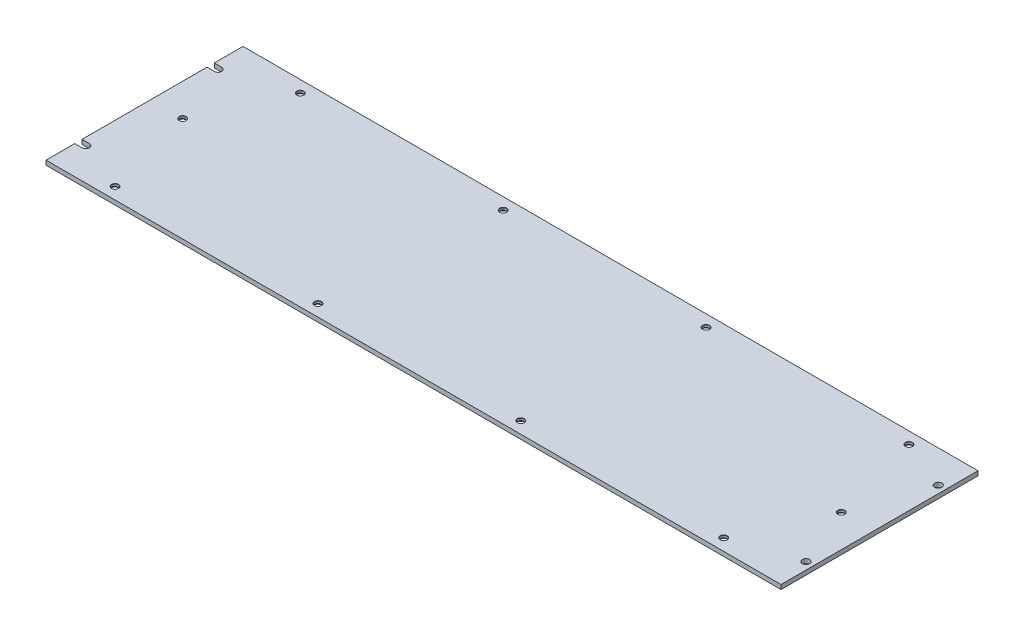
from build123d import *

# Parameters (mm, degrees)
SKETCH_2_W                  = 500
SKETCH_2_H                  = 134
EXTRUDE_1_DEPTH             = 3
SKETCH_3_R                  = 2.5
CUT_EXTRUDE_1_DEPTH         = 4
HOLE_WIZARD_M41_AT_2_COUNT  = 2
HOLE_WIZARD_M41_AT_2_PITCH  = 138
HOLE_WIZARD_M41_AT_3_COUNT  = 2
HOLE_WIZARD_M41_AT_3_PITCH  = 167.314075917
HOLE_WIZARD_M41_AT_4_COUNT  = 2
HOLE_WIZARD_M41_AT_4_PITCH  = 175.567650779
HOLE_WIZARD_M41_AT_5_COUNT  = 2
HOLE_WIZARD_M41_AT_5_PITCH  = 118.270875536
HOLE_WIZARD_M41_AT_6_COUNT  = 2
HOLE_WIZARD_M41_AT_6_PITCH  = 187.723200484
HOLE_WIZARD_M41_AT_7_COUNT  = 2
HOLE_WIZARD_M41_AT_7_PITCH  = 307.538615462
HOLE_WIZARD_M41_AT_8_COUNT  = 2
HOLE_WIZARD_M41_AT_8_PITCH  = 305.983659694
HOLE_WIZARD_M41_AT_9_COUNT  = 2
HOLE_WIZARD_M41_AT_9_PITCH  = 276
HOLE_WIZARD_M41_AT_10_COUNT = 2
HOLE_WIZARD_M41_AT_10_PITCH = 138


with BuildPart() as part:
    # Эскиз2 → Бобышка-Вытянуть1 (new body)
    with BuildSketch(Plane(origin=(0, 0, 0), x_dir=(1, 0, 0), z_dir=(0, 1, 0))):
        with Locations((250, 67)):
            Rectangle(SKETCH_2_W, SKETCH_2_H)
    extrude(amount=EXTRUDE_1_DEPTH)

    # Эскиз3 → Вырез-Вытянуть1 (cut, through all)
    with BuildSketch(Plane(origin=(0, 3, 0), x_dir=(1, 0, 0), z_dir=(0, 1, 0))):
        with BuildLine():
            ThreePointArc((5, 109.5), (7.5, 112), (5, 114.5))
            Line((5, 114.5), (0, 114.5))
            Line((0, 114.5), (0, 109.5))
            Line((0, 109.5), (5, 109.5))
        make_face()
        with BuildLine():
            Line((5, 24.5), (0, 24.5))
            Line((0, 24.5), (0, 19.5))
            Line((0, 19.5), (5, 19.5))
            ThreePointArc((5, 19.5), (7.5, 22), (5, 24.5))
        make_face()
        with Locations((495, 22)):
            Circle(SKETCH_3_R)
        with Locations((495, 112)):
            Circle(SKETCH_3_R)
    extrude(amount=-CUT_EXTRUDE_1_DEPTH, mode=Mode.SUBTRACT)

    # Эскиз4 → Зенковка для винта с потайной головкой M41 (revolve, cut)
    with BuildSketch(Plane(origin=(177, 0, -8), x_dir=(0, 0, -1), z_dir=(1, 0, 0))):
        Polygon((0, 0), (0, 3), (2.4, 3), (2.25, 2.85), (2.25, 1.45), (3.7, 0), align=None)
    hole_wizard_m41 = revolve(axis=Axis((177, -6.35, -8), (0, 1, 0)), mode=Mode.SUBTRACT)

    # Зенковка для винта с потайной головкой M41 at 2: Зенковка для винта с потайной головкой M41 ×2
    with Locations(*[(-i * HOLE_WIZARD_M41_AT_2_PITCH, 0, 0) for i in range(1, HOLE_WIZARD_M41_AT_2_COUNT)]):
        add(hole_wizard_m41, mode=Mode.SUBTRACT)

    # Зенковка для винта с потайной головкой M41 at 3: Зенковка для винта с потайной головкой M41 ×2
    with Locations(*[Vector(-0.926401435, 0, -0.376537357) * (i * HOLE_WIZARD_M41_AT_3_PITCH) for i in range(1, HOLE_WIZARD_M41_AT_3_COUNT)]):
        add(hole_wizard_m41, mode=Mode.SUBTRACT)

    # Зенковка для винта с потайной головкой M41 at 4: Зенковка для винта с потайной головкой M41 ×2
    with Locations(*[Vector(-0.740455314, 0, -0.672105593) * (i * HOLE_WIZARD_M41_AT_4_PITCH) for i in range(1, HOLE_WIZARD_M41_AT_4_COUNT)]):
        add(hole_wizard_m41, mode=Mode.SUBTRACT)

    # Зенковка для винта с потайной головкой M41 at 5: Зенковка для винта с потайной головкой M41 ×2
    with Locations(*[Vector(0.067641336, 0, -0.997709702) * (i * HOLE_WIZARD_M41_AT_5_PITCH) for i in range(1, HOLE_WIZARD_M41_AT_5_COUNT)]):
        add(hole_wizard_m41, mode=Mode.SUBTRACT)

    # Зенковка для винта с потайной головкой M41 at 6: Зенковка для винта с потайной головкой M41 ×2
    with Locations(*[Vector(0.777740842, 0, -0.628585064) * (i * HOLE_WIZARD_M41_AT_6_PITCH) for i in range(1, HOLE_WIZARD_M41_AT_6_COUNT)]):
        add(hole_wizard_m41, mode=Mode.SUBTRACT)

    # Зенковка для винта с потайной головкой M41 at 7: Зенковка для винта с потайной головкой M41 ×2
    with Locations(*[Vector(0.923461269, 0, -0.383691654) * (i * HOLE_WIZARD_M41_AT_7_PITCH) for i in range(1, HOLE_WIZARD_M41_AT_7_COUNT)]):
        add(hole_wizard_m41, mode=Mode.SUBTRACT)

    # Зенковка для винта с потайной головкой M41 at 8: Зенковка для винта с потайной головкой M41 ×2
    with Locations(*[Vector(0.983712661, 0, -0.179748161) * (i * HOLE_WIZARD_M41_AT_8_PITCH) for i in range(1, HOLE_WIZARD_M41_AT_8_COUNT)]):
        add(hole_wizard_m41, mode=Mode.SUBTRACT)

    # Зенковка для винта с потайной головкой M41 at 9: Зенковка для винта с потайной головкой M41 ×2
    with Locations(*[(i * HOLE_WIZARD_M41_AT_9_PITCH, 0, 0) for i in range(1, HOLE_WIZARD_M41_AT_9_COUNT)]):
        add(hole_wizard_m41, mode=Mode.SUBTRACT)

    # Зенковка для винта с потайной головкой M41 at 10: Зенковка для винта с потайной головкой M41 ×2
    with Locations(*[(i * HOLE_WIZARD_M41_AT_10_PITCH, 0, 0) for i in range(1, HOLE_WIZARD_M41_AT_10_COUNT)]):
        add(hole_wizard_m41, mode=Mode.SUBTRACT)


solid = part.part
